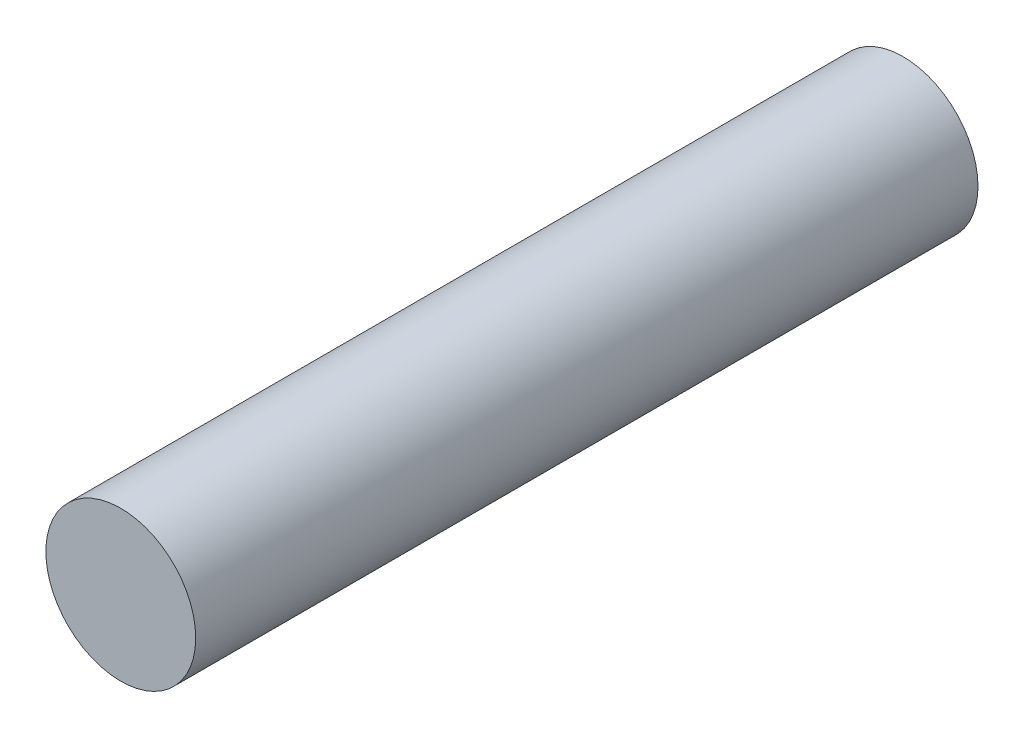
from build123d import *

# Parameters (mm, degrees)
SKETCH1_R           = 1.58115
BOSS_EXTRUDE1_DEPTH = 16.51


with BuildPart() as part:
    # Sketch1 → Boss-Extrude1 (new body)
    with BuildSketch(Plane.XY):
        Circle(SKETCH1_R)
    extrude(amount=BOSS_EXTRUDE1_DEPTH)


solid = part.part
